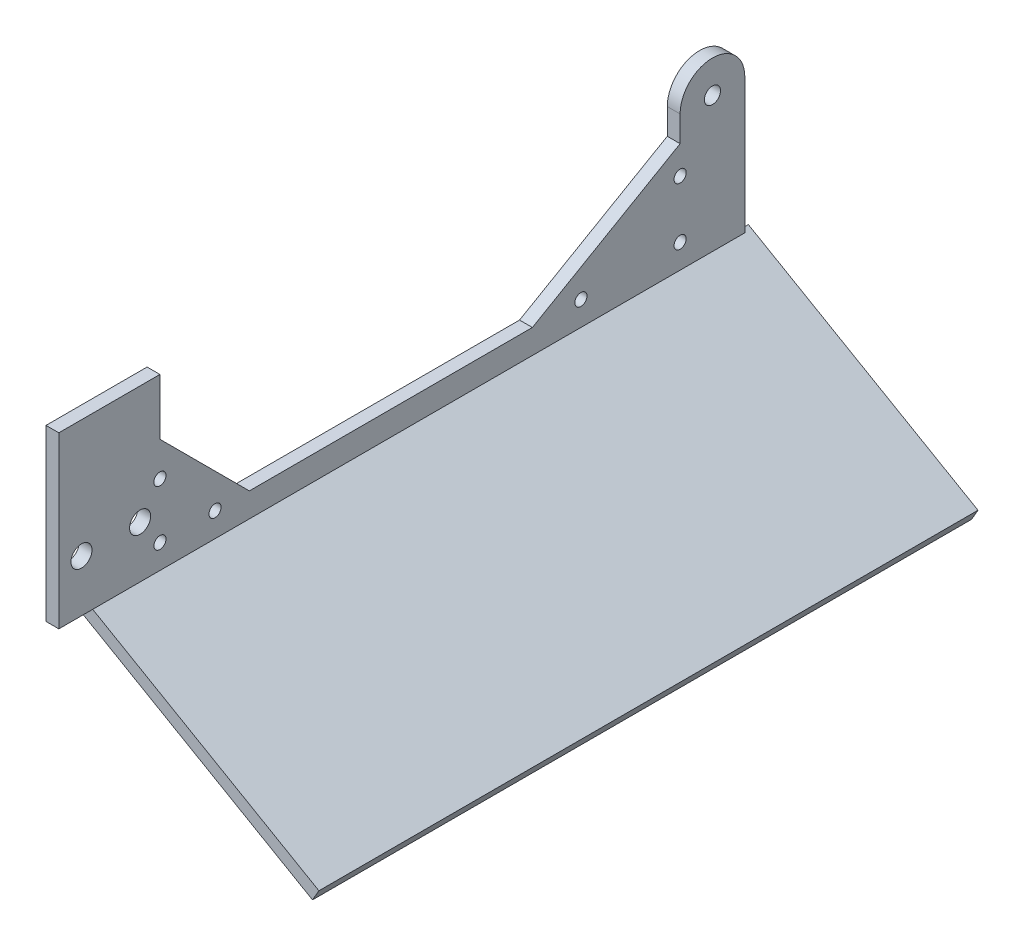
from build123d import *

# Parameters (mm, degrees)
SKETCH11_W          = 163
SKETCH11_H          = 65.580816733
BOSS_EXTRUDE2_DEPTH = 3.175
SKETCH12_R          = 1.5
SKETCH12_R_2        = 2
SKETCH12_R_3        = 2.6
BOSS_EXTRUDE3_DEPTH = 3.175


with BuildPart() as part:
    # Sketch11 → Boss-Extrude2 (new body)
    with BuildSketch(Plane(origin=(0, 0, 0), x_dir=(0, 0, -1), z_dir=(-0.5, -0.866025404, 0))):
        with Locations((81.5, 32.790408367)):
            Rectangle(SKETCH11_W, SKETCH11_H)
    extrude(amount=-BOSS_EXTRUDE2_DEPTH)


with BuildPart() as body_2:
    # Sketch12 → Boss-Extrude3 (new body)
    with BuildSketch(Plane(origin=(0, 0, 0), x_dir=(0, 0, -1), z_dir=(1, 0, 0))):
        with BuildLine():
            Line((-9.115081699, 45), (15.884918301, 45))
            Line((15.884918301, 45), (15.884918301, 31.115081699))
            Line((15.884918301, 31.115081699), (38, 9))
            Line((38, 9), (108, 9))
            Line((108, 9), (144.534918301, 30.093444916))
            Line((144.534918301, 30.093444916), (144.534918301, 36.464807754))
            ThreePointArc((144.534918301, 36.464807754), (152.534918301, 44.464807754), (160.534918301, 36.464807754))
            Line((160.534918301, 36.464807754), (160.534918301, 3))
            Line((160.534918301, 3), (-9.115081699, 3))
            Line((-9.115081699, 3), (-9.115081699, 45))
        make_face()
        with Locations((15.884918301, 22.629800325)):
            Circle(SKETCH12_R, mode=Mode.SUBTRACT)
        with Locations((120, 9)):
            Circle(SKETCH12_R, mode=Mode.SUBTRACT)
        with Locations((144.534918301, 23.165241686)):
            Circle(SKETCH12_R, mode=Mode.SUBTRACT)
        with Locations((29.514718626, 9)):
            Circle(SKETCH12_R, mode=Mode.SUBTRACT)
        with Locations((15.884918301, 9)):
            Circle(SKETCH12_R, mode=Mode.SUBTRACT)
        with Locations((144.534918301, 9)):
            Circle(SKETCH12_R, mode=Mode.SUBTRACT)
        with Locations((152.534918301, 36.464807754)):
            Circle(SKETCH12_R_2, mode=Mode.SUBTRACT)
        with Locations((-3.515081699, 15.814900162)):
            Circle(SKETCH12_R_3, mode=Mode.SUBTRACT)
        with Locations((10.984918301, 15.814900162)):
            Circle(SKETCH12_R_3, mode=Mode.SUBTRACT)
    extrude(amount=BOSS_EXTRUDE3_DEPTH)


solid = Compound([part.part, body_2.part])
